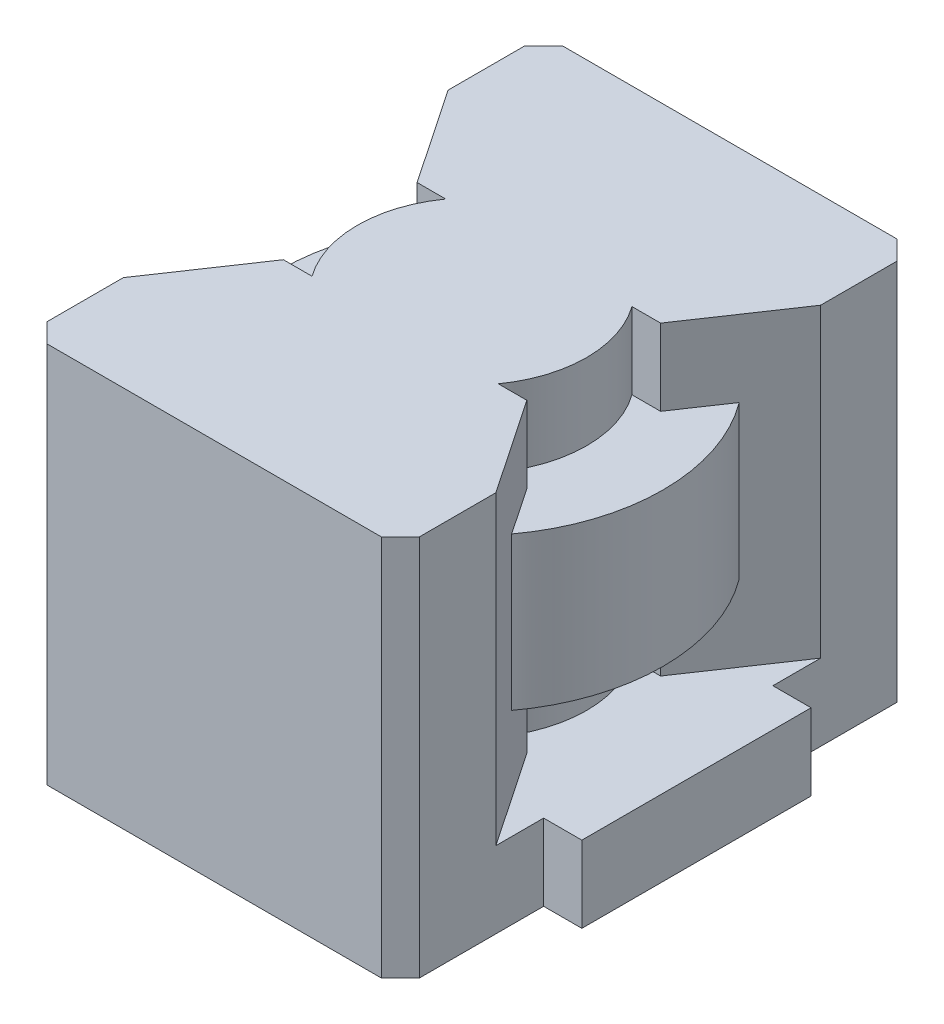
from build123d import *

# Parameters (mm, degrees)
SKETCH1_W           = 2
SKETCH1_H           = 12
SKETCH1_W_2         = 19.5
SKETCH1_H_2         = 27
BOSS_EXTRUDE1_DEPTH = 4
SKETCH2_W           = 19.5
SKETCH2_H           = 5
SKETCH2_R           = 6
BOSS_EXTRUDE2_DEPTH = 16
BOSS_EXTRUDE3_START = 4
SKETCH3_R           = 10
BOSS_EXTRUDE3_DEPTH = 8
CHAMFER1_SIZE       = 1


with BuildPart() as part:
    # Sketch1 → Boss-Extrude1 (new body)
    with BuildSketch(Plane(origin=(0, 0, 0), x_dir=(1, 0, 0), z_dir=(0, 1, 0))):
        with Locations((-10.75, 0)):
            Rectangle(SKETCH1_W, SKETCH1_H)
        Rectangle(SKETCH1_W_2, SKETCH1_H_2)
        with Locations((10.75, 0)):
            Rectangle(SKETCH1_W, SKETCH1_H)
    extrude(amount=BOSS_EXTRUDE1_DEPTH)

    # Sketch2 → Boss-Extrude2 (add)
    with BuildSketch(Plane(origin=(0, 4, 0), x_dir=(1, 0, 0), z_dir=(0, 1, 0))):
        with BuildLine():
            Line((-6.373397172, 3.5), (-4.873397172, 3.5))
            ThreePointArc((-4.873397172, 3.5), (0, 6), (4.873397172, 3.5))
            Line((4.873397172, 3.5), (6.373397172, 3.5))
            Line((6.373397172, 3.5), (9.75, 8.5))
            Line((9.75, 8.5), (-9.75, 8.5))
            Line((-9.75, 8.5), (-6.373397172, 3.5))
        make_face()
        with Locations((0, 11)):
            Rectangle(SKETCH2_W, SKETCH2_H)
        Circle(SKETCH2_R)
        with BuildLine():
            Line((-6.373397172, -3.5), (-9.75, -8.5))
            Line((-9.75, -8.5), (9.75, -8.5))
            Line((9.75, -8.5), (6.373397172, -3.5))
            Line((6.373397172, -3.5), (4.873397172, -3.5))
            ThreePointArc((4.873397172, -3.5), (0, -6), (-4.873397172, -3.5))
            Line((-4.873397172, -3.5), (-6.373397172, -3.5))
        make_face()
        with Locations((0, -11)):
            Rectangle(SKETCH2_W, SKETCH2_H)
    extrude(amount=BOSS_EXTRUDE2_DEPTH)

    # Sketch3 → Boss-Extrude3 (add)
    with BuildSketch(Plane(origin=(0, 4, 0), x_dir=(1, 0, 0), z_dir=(0, 1, 0)).offset(BOSS_EXTRUDE3_START)):
        Circle(SKETCH3_R)
    extrude(amount=BOSS_EXTRUDE3_DEPTH)

    # Chamfer1
    chamfer1_edges = [part.edges().sort_by_distance(p)[0] for p in [
        (-9.75, 10, -13.5),
        (9.75, 10, -13.5),
        (9.75, 10, 13.5),
        (-9.75, 10, 13.5),
    ]]
    chamfer(chamfer1_edges, length=CHAMFER1_SIZE)


solid = part.part
